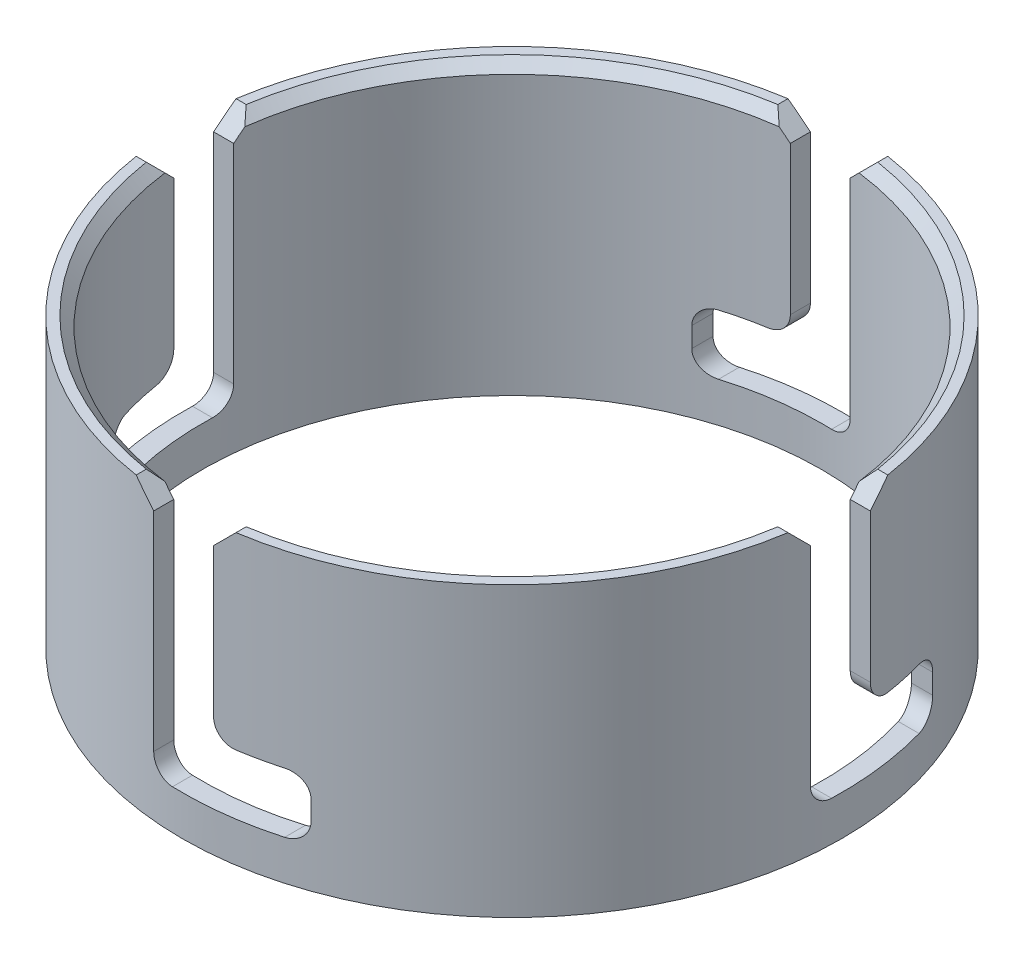
from build123d import *

# Parameters (mm, degrees)
SKETCH2_W                    = 5
SKETCH2_H                    = 72.15
CUT_EXTRUDE1_DEPTH           = 83.55
FILLET1_R                    = 5
CHAMFER1_SIZE                = 5
FILLET3_R                    = 5
CIRPATTERN1_COUNT            = 4
FILLET1_OF_CIRPATTERN1_R     = 5
CHAMFER1_OF_CIRPATTERN1_SIZE = 5
FILLET3_OF_CIRPATTERN1_R     = 5
CHAMFER2_SIZE                = 2.5


with BuildPart() as part:
    # Sketch2 → Revolve1 (revolve)
    with BuildSketch(Plane(origin=(0, 0, 0), x_dir=(0, 0, -1), z_dir=(1, 0, 0))):
        with Locations((-80.05, 36.075)):
            Rectangle(SKETCH2_W, SKETCH2_H)
    revolve(axis=Axis((0, -3.6075, 0), (0, 1, 0)))

    # Sketch3 → Cut-Extrude1 (cut, through all)
    with BuildSketch(Plane(origin=(0, 0, 0), x_dir=(0, 0, -1), z_dir=(1, 0, 0))):
        Polygon((-7.5, 72.15), (7.5, 72.15), (7.5, 10), (-27.5, 10), (-27.5, 25), (-7.5, 25), align=None)
    cut_extrude1 = extrude(amount=-CUT_EXTRUDE1_DEPTH, mode=Mode.SUBTRACT)

    # Fillet1
    fillet1_edges = [part.edges().sort_by_distance(p)[0] for p in [
        (-79.697535069, 10, -7.5),
        (-79.697535069, 25, 7.5),
    ]]
    fillet(fillet1_edges, radius=FILLET1_R)

    # Chamfer1
    chamfer1_edges = [part.edges().sort_by_distance(p)[0] for p in [
        (-79.697535069, 72.15, -7.5),
        (-79.697535069, 72.15, 7.5),
    ]]
    chamfer(chamfer1_edges, length=CHAMFER1_SIZE)

    # Fillet3
    fillet3_edges = [part.edges().sort_by_distance(p)[0] for p in [
        (-75.17256913, 10, 27.5),
        (-75.17256913, 25, 27.5),
    ]]
    fillet(fillet3_edges, radius=FILLET3_R)

    # CirPattern1: Cut-Extrude1 ×4 about axis
    cirpattern1_axis = Axis((0, 0, 0), (0, 1, 0))
    for i in range(1, CIRPATTERN1_COUNT):
        add(cut_extrude1.rotate(cirpattern1_axis, i * 360 / CIRPATTERN1_COUNT), mode=Mode.SUBTRACT)

    # Fillet1 of CirPattern1
    fillet1_of_cirpattern1_edges = [part.edges().sort_by_distance(p)[0] for p in [
        (-7.5, 10, 79.697535069),
        (7.5, 25, 79.697535069),
        (79.697535069, 10, 7.5),
        (79.697535069, 25, -7.5),
        (7.5, 10, -79.697535069),
        (-7.5, 25, -79.697535069),
    ]]
    fillet(fillet1_of_cirpattern1_edges, radius=FILLET1_OF_CIRPATTERN1_R)

    # Chamfer1 of CirPattern1
    chamfer1_of_cirpattern1_edges = [part.edges().sort_by_distance(p)[0] for p in [
        (-7.5, 72.15, 79.697535069),
        (7.5, 72.15, 79.697535069),
        (79.697535069, 72.15, 7.5),
        (79.697535069, 72.15, -7.5),
        (7.5, 72.15, -79.697535069),
        (-7.5, 72.15, -79.697535069),
    ]]
    chamfer(chamfer1_of_cirpattern1_edges, length=CHAMFER1_OF_CIRPATTERN1_SIZE)

    # Fillet3 of CirPattern1
    fillet3_of_cirpattern1_edges = [part.edges().sort_by_distance(p)[0] for p in [
        (27.5, 10, 75.17256913),
        (27.5, 25, 75.17256913),
        (75.17256913, 10, -27.5),
        (75.17256913, 25, -27.5),
        (-27.5, 10, -75.17256913),
        (-27.5, 25, -75.17256913),
    ]]
    fillet(fillet3_of_cirpattern1_edges, radius=FILLET3_OF_CIRPATTERN1_R)

    # Chamfer2
    chamfer2_edges = [part.edges().sort_by_distance(p)[0] for p in [
        (-54.836130881, 72.15, -54.836130881),
        (54.836130881, 72.15, -54.836130881),
        (54.836130881, 72.15, 54.836130881),
        (-54.836130881, 72.15, 54.836130881),
    ]]
    chamfer(chamfer2_edges, length=CHAMFER2_SIZE)


solid = part.part
